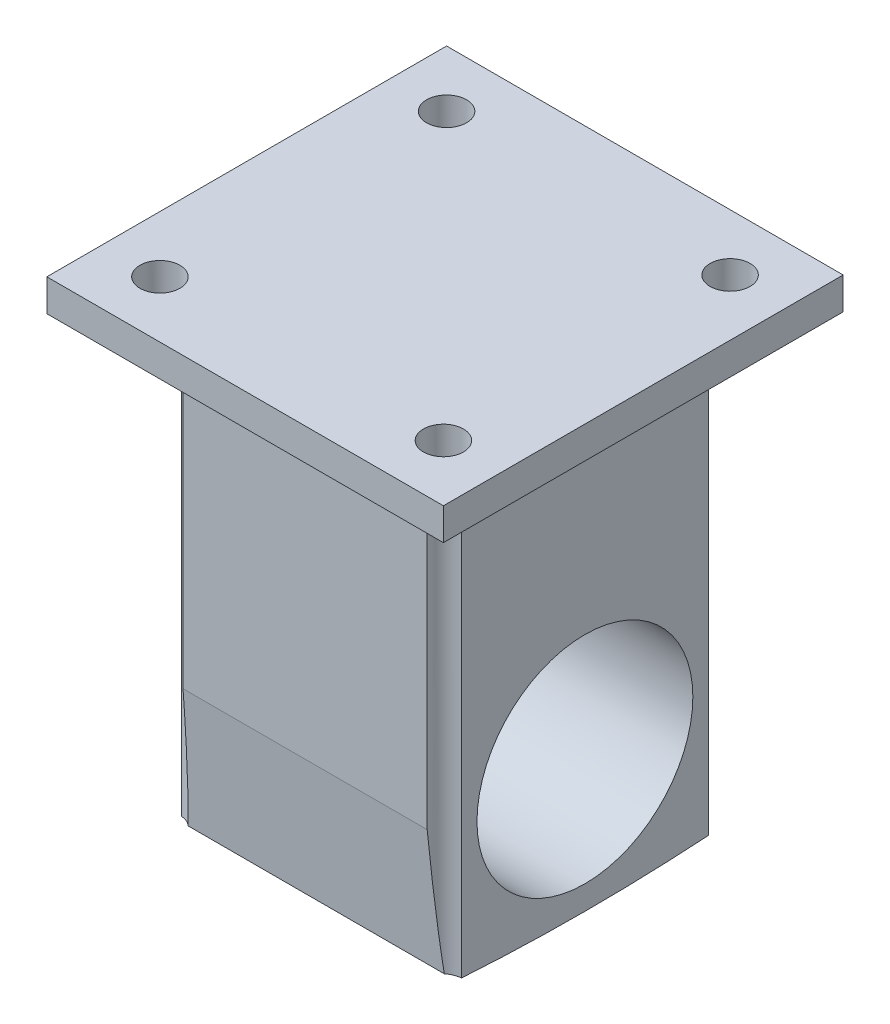
from build123d import *

# Parameters (mm, degrees)
SKETCH1_W           = 44.45
SKETCH1_H           = 44.45
BOSS_EXTRUDE1_DEPTH = 50.292
BOSS_EXTRUDE2_DEPTH = 44.45
SKETCH3_R           = 17.145
CUT_EXTRUDE1_DEPTH  = 127
SKETCH4_W           = 62.992
SKETCH4_H           = 63.5
BOSS_EXTRUDE3_DEPTH = 5.08
SKETCH5_R           = 3.175
CUT_EXTRUDE2_DEPTH  = 77.312793071


with BuildPart() as part:
    # Sketch1 → Boss-Extrude1 (new body)
    with BuildSketch(Plane(origin=(0, 0, 0), x_dir=(1, 0, 0), z_dir=(0, 1, 0))):
        Rectangle(SKETCH1_W, SKETCH1_H)
    extrude(amount=BOSS_EXTRUDE1_DEPTH)

    # Sketch2 → Boss-Extrude2 (add)
    with BuildSketch(Plane(origin=(22.225, 0, 0), x_dir=(0, 0, -1), z_dir=(1, 0, 0))):
        with BuildLine():
            Line((-22.225, 0), (-20.453995307, -20.242676265))
            ThreePointArc((-20.453995307, -20.242676265), (0, -20.940793071), (20.453995307, -20.242676265))
            Line((20.453995307, -20.242676265), (22.225, 0))
            Line((22.225, 0), (-22.225, 0))
        make_face()
    extrude(amount=-BOSS_EXTRUDE2_DEPTH)

    # Sketch3 → Cut-Extrude1 (cut)
    with BuildSketch(Plane(origin=(22.225, 0, 0), x_dir=(0, 0, -1), z_dir=(1, 0, 0))):
        Circle(SKETCH3_R)
    extrude(amount=-CUT_EXTRUDE1_DEPTH, mode=Mode.SUBTRACT)

    # Sketch4 → Boss-Extrude3 (add)
    with BuildSketch(Plane(origin=(0, 50.292, 0), x_dir=(1, 0, 0), z_dir=(0, 1, 0))):
        Rectangle(SKETCH4_W, SKETCH4_H)
    extrude(amount=BOSS_EXTRUDE3_DEPTH)

    # Sketch5 → Cut-Extrude2 (cut, through all)
    with BuildSketch(Plane(origin=(0, 55.372, 0), x_dir=(1, 0, 0), z_dir=(0, 1, 0))):
        with Locations((-22.515743879, 22.769743879)):
            Circle(SKETCH5_R)
        with Locations((22.515743879, 22.769743879)):
            Circle(SKETCH5_R)
        with Locations((-22.515743879, -22.769743879)):
            Circle(SKETCH5_R)
        with Locations((22.515743879, -22.769743879)):
            Circle(SKETCH5_R)
    extrude(amount=-CUT_EXTRUDE2_DEPTH, mode=Mode.SUBTRACT)


solid = part.part
